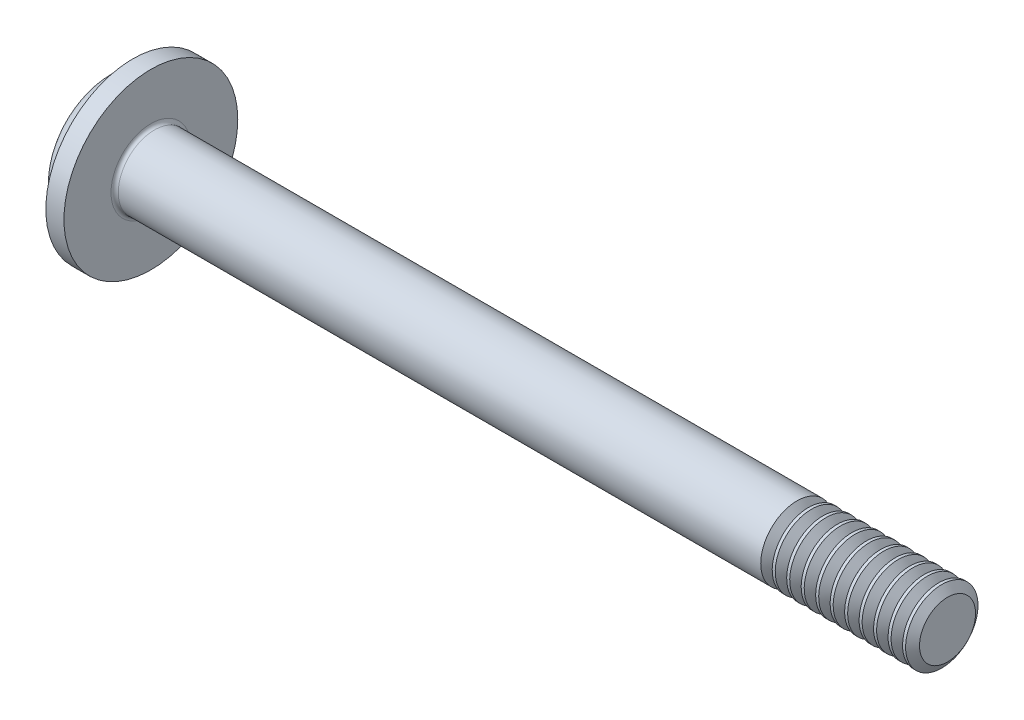
from build123d import *

# Parameters (mm, degrees)
FILLET1_R                = 0.1
SKETCH3_W                = 0.48
SKETCH3_H                = 2.1
SKETCH4_W                = 0.48
SKETCH4_H                = 0.68402847
RECPAT_COUNT             = 2
RECPAT_ANGLE             = 90
THDSCHPAT_COUNT          = 11
THDSCHPAT_PITCH          = 0.4
ESBO_O1_R                = 2.4
RESSALTO_EXTRUS_O1_DEPTH = 0.5


with BuildPart() as part:
    # BodySke → Base-Revolve (revolve)
    with BuildSketch(Plane.XY):
        with BuildLine():
            Line((1.6, 1), (1.6, 2))
            Line((1.6, 2), (1.1, 2))
            ThreePointArc((1.1, 2), (0.688403396, 1.885994341), (0.394117647, 1.576470588))
            ThreePointArc((0.394117647, 1.576470588), (0.100022625, 0.812494344), (0, 0))
            Line((0, 0), (23.6, 0))
            Line((23.6, 0), (23.6, 1))
            Line((23.6, 1), (1.6, 1))
        make_face()
    revolve(axis=Axis((-25.4, 0, 0), (1, 0, 0)))

    # Fillet1
    fillet1_edges = [part.edges().sort_by_distance(p)[0] for p in [
        (1.6, -1, 0),
    ]]
    fillet(fillet1_edges, radius=FILLET1_R)

    # Sketch3 → Recess section 0
    with BuildSketch(Plane(origin=(0, 0, 0), x_dir=(0, 0, -1), z_dir=(1, 0, 0))):
        Rectangle(SKETCH3_W, SKETCH3_H)
    # Sketch4 → Recess section 1
    with BuildSketch(Plane(origin=(1.42, 0, 0), x_dir=(0, 0, -1), z_dir=(1, 0, 0))):
        Rectangle(SKETCH4_W, SKETCH4_H)
    recess = loft(mode=Mode.SUBTRACT)

    # RecPat: Recess ×2 about axis
    recpat_axis = Axis((0, 0, 0), (1, 0, 0))
    for i in range(1, RECPAT_COUNT):
        add(recess.rotate(recpat_axis, i * RECPAT_ANGLE / (RECPAT_COUNT - 1)), mode=Mode.SUBTRACT)

    # RecCorSke → RecessCore (revolve, cut)
    with BuildSketch(Plane.XY):
        Polygon((0, 0), (0, 0.454796073), (1.42, 0.3555), (1.535508952, 0), align=None)
    revolve(axis=Axis((-3.175, 0, 0), (1, 0, 0)), mode=Mode.SUBTRACT)

    # ThdSchSke → ThreadSchematic (revolve, cut)
    with BuildSketch(Plane.XY):
        Polygon((19.6, -0.774), (19.441753096, -1), (19.441753096, -1.25), (19.758246904, -1.25), (19.758246904, -1), align=None)
    threadschematic = revolve(axis=Axis((-3.175, 0, 0), (1, 0, 0)), mode=Mode.SUBTRACT)

    # ThdSchPat: ThreadSchematic ×11
    with Locations(*[(i * THDSCHPAT_PITCH, 0, 0) for i in range(1, THDSCHPAT_COUNT)]):
        add(threadschematic, mode=Mode.SUBTRACT)

    # Esboço1 → Ressalto-extrusão1 (add)
    with BuildSketch(Plane(origin=(1.6, 0, 0), x_dir=(0, 0, -1), z_dir=(1, 0, 0))):
        Circle(ESBO_O1_R)
    extrude(amount=-RESSALTO_EXTRUS_O1_DEPTH)


solid = part.part
